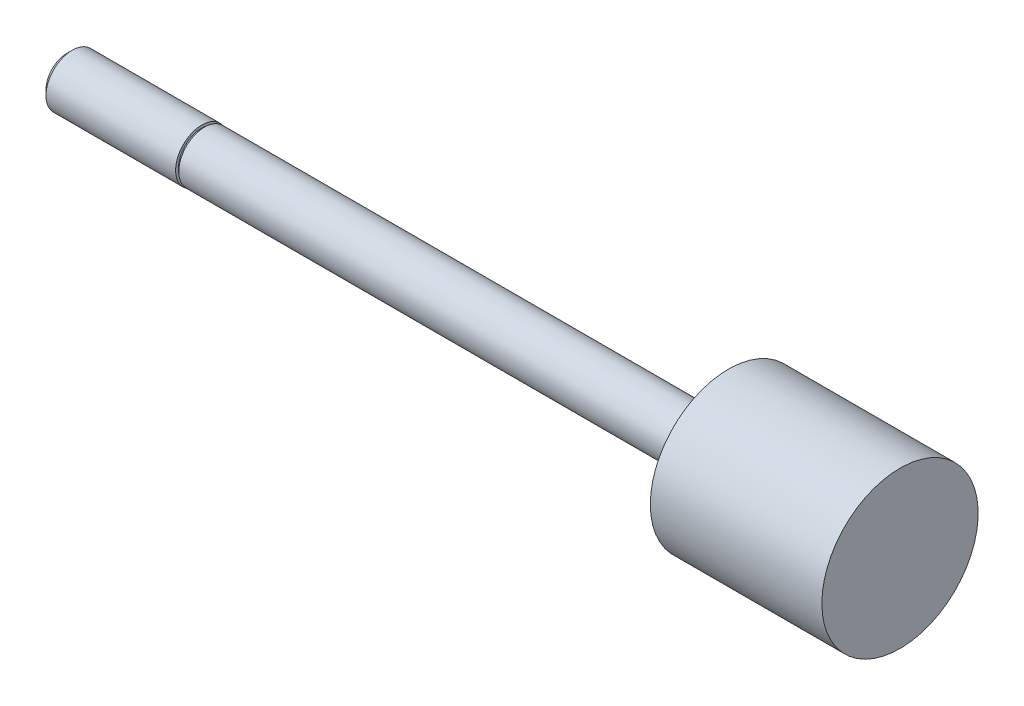
from build123d import *

# Parameters (mm, degrees)
SKETCH3_W = 0.254
SKETCH3_H = 0.508


with BuildPart() as part:
    # Sketch1 → Revolve1 (revolve)
    with BuildSketch(Plane.XY):
        Polygon((0, 0), (0, 2.3749), (48.4124, 2.3749), (48.4124, 7.21995), (64.262, 7.21995), (64.262, 0), align=None)
    revolve(axis=Axis((64.262, 0, 0), (-1, 0, 0)))

    # Sketch2 → Revolve2 (revolve)
    with BuildSketch(Plane.XY):
        Polygon((-12.7, 0), (-12.7, 1.94056), (-12.22756, 2.413), (0, 2.413), (0, 0), align=None)
    revolve(axis=Axis((0, 0, 0), (-1, 0, 0)))

    # Sketch3 → Cut-Revolve1 (revolve, cut)
    with BuildSketch(Plane.XY):
        with Locations((-0.127, 2.413)):
            Rectangle(SKETCH3_W, SKETCH3_H)
    revolve(axis=Axis((0, 0, 0), (-1, 0, 0)), mode=Mode.SUBTRACT)


solid = part.part
